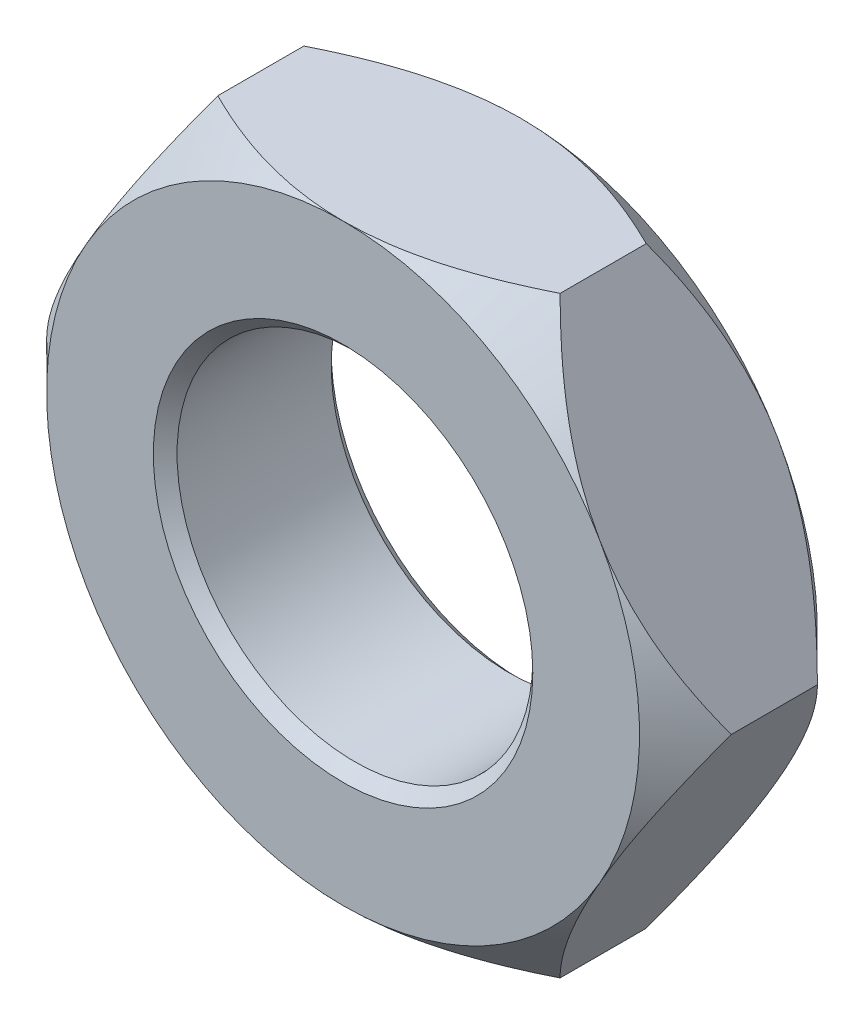
from build123d import *

# Parameters (mm, degrees)
SKETCH_1_R          = 3
EXTRUDE_1_DEPTH     = 3
CHAMFER_1_SIZE      = 0.2
SKETCH_2_OUTSIDE_W  = 22.662
SKETCH_2_OUTSIDE_H  = 21.114
SKETCH_2_OUTSIDE_R  = 5
CUT_EXTRUDE_1_DEPTH = 3
CUT_EXTRUDE_1_TAPER = 45
SKETCH_3_OUTSIDE_W  = 22.662
SKETCH_3_OUTSIDE_H  = 21.114
SKETCH_3_OUTSIDE_R  = 5
CUT_EXTRUDE_2_DEPTH = 3
CUT_EXTRUDE_2_TAPER = 45


with BuildPart() as part:
    # Эскиз1 → Бобышка-Вытянуть1 (new body)
    with BuildSketch(Plane.XY):
        Polygon((5.773502692, 0), (2.886751346, 5), (-2.886751346, 5), (-5.773502692, 0), (-2.886751346, -5), (2.886751346, -5), align=None)
        Circle(SKETCH_1_R, mode=Mode.SUBTRACT)
    extrude(amount=EXTRUDE_1_DEPTH)

    # Фаска1
    chamfer_1_edges = [part.edges().sort_by_distance(p)[0] for p in [
        (-3, 0, 0),
        (-3, 0, 3),
    ]]
    chamfer(chamfer_1_edges, length=CHAMFER_1_SIZE)

    # Эскиз2 outside → Вырез-Вытянуть1 (cut)
    with BuildSketch(Plane.XY.offset(3)):
        Rectangle(SKETCH_2_OUTSIDE_W, SKETCH_2_OUTSIDE_H)
        Circle(SKETCH_2_OUTSIDE_R, mode=Mode.SUBTRACT)
    extrude(amount=-CUT_EXTRUDE_1_DEPTH, taper=CUT_EXTRUDE_1_TAPER, mode=Mode.SUBTRACT)

    # Эскиз3 outside → Вырез-Вытянуть2 (cut)
    with BuildSketch(Plane(origin=(0, 0, 0), x_dir=(-1, 0, 0), z_dir=(0, 0, -1))):
        Rectangle(SKETCH_3_OUTSIDE_W, SKETCH_3_OUTSIDE_H)
        Circle(SKETCH_3_OUTSIDE_R, mode=Mode.SUBTRACT)
    extrude(amount=-CUT_EXTRUDE_2_DEPTH, taper=CUT_EXTRUDE_2_TAPER, mode=Mode.SUBTRACT)


solid = part.part
